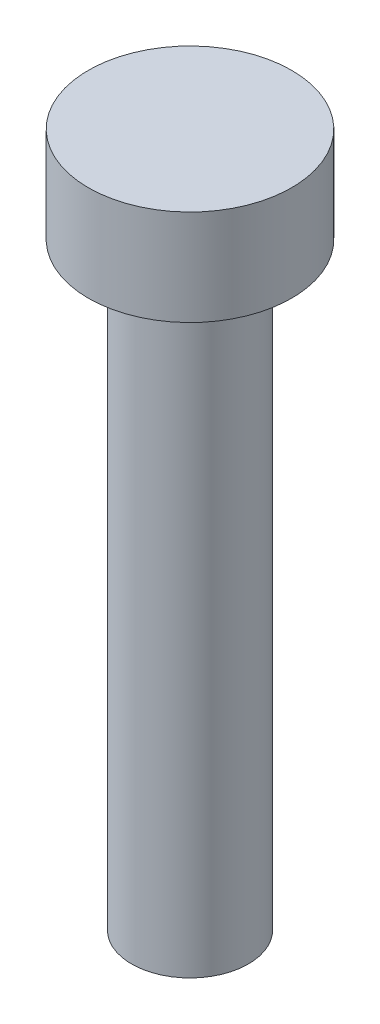
from build123d import *

# Parameters (mm, degrees)
SKETCH1_R           = 4.25
BOSS_EXTRUDE1_DEPTH = 4
SKETCH2_R           = 2.44
BOSS_EXTRUDE2_DEPTH = 25


with BuildPart() as part:
    # Sketch1 → Boss-Extrude1 (new body)
    with BuildSketch(Plane(origin=(0, 0, 0), x_dir=(1, 0, 0), z_dir=(0, 1, 0))):
        Circle(SKETCH1_R)
    extrude(amount=BOSS_EXTRUDE1_DEPTH)

    # Sketch2 → Boss-Extrude2 (add)
    with BuildSketch(Plane.XZ):
        Circle(SKETCH2_R)
    extrude(amount=BOSS_EXTRUDE2_DEPTH)


solid = part.part
